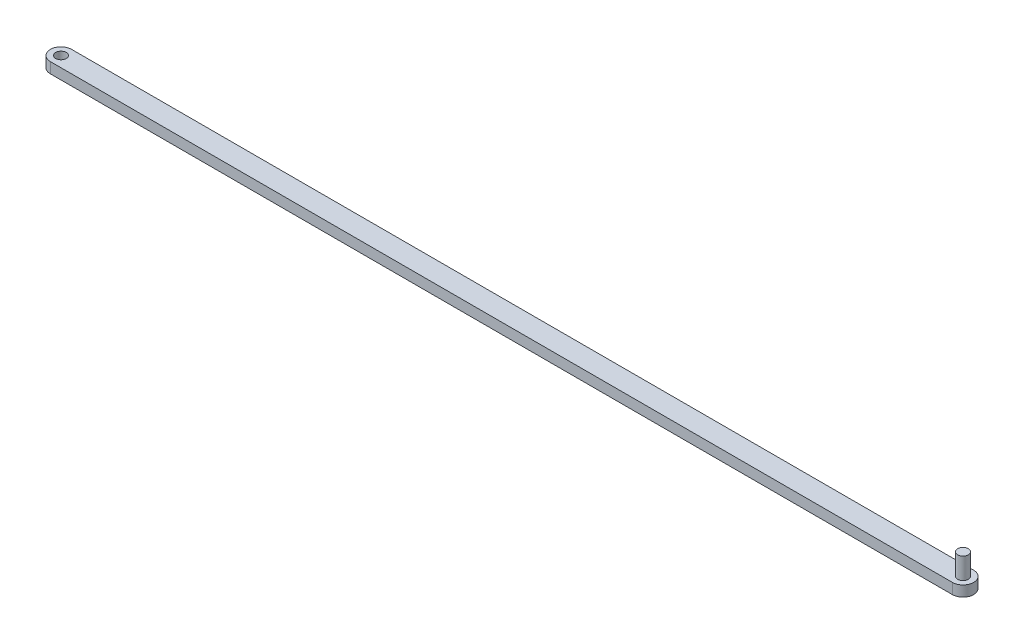
from build123d import *

# Parameters (mm, degrees)
SKETCH5_R           = 5
BOSS_EXTRUDE1_DEPTH = 10
SKETCH7_R           = 5
BOSS_EXTRUDE2_DEPTH = 20


with BuildPart() as part:
    # Sketch5 → Boss-Extrude1 (new body)
    with BuildSketch(Plane(origin=(0, 0, 0), x_dir=(1, 0, 0), z_dir=(0, 1, 0))):
        with BuildLine():
            Line((-425, 10), (425, 10))
            ThreePointArc((425, 10), (435, 0), (425, -10))
            Line((425, -10), (-425, -10))
            ThreePointArc((-425, -10), (-435, 0), (-425, 10))
        make_face()
        with Locations((-425, 0)):
            Circle(SKETCH5_R, mode=Mode.SUBTRACT)
    extrude(amount=-BOSS_EXTRUDE1_DEPTH)

    # Sketch7 → Boss-Extrude2 (add)
    with BuildSketch(Plane(origin=(0, 0, 0), x_dir=(1, 0, 0), z_dir=(0, 1, 0))):
        with Locations((425, 0)):
            Circle(SKETCH7_R)
    extrude(amount=BOSS_EXTRUDE2_DEPTH)


solid = part.part
